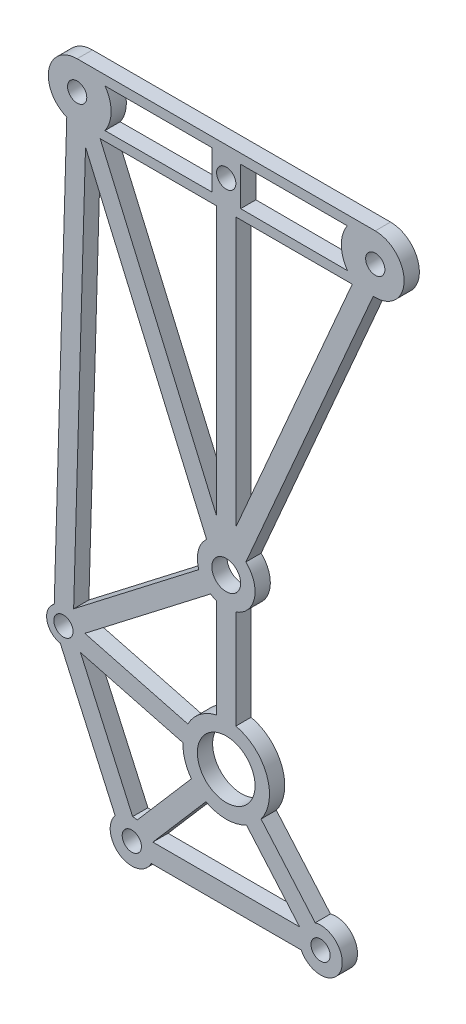
from build123d import *

# Parameters (mm, degrees)
SKETCH3_R           = 3
SKETCH3_R_2         = 1
SKETCH3_R_3         = 1.500000001
BOSS_EXTRUDE1_DEPTH = 1.5875


with BuildPart() as part:
    # Sketch3 → Boss-Extrude1 (new body)
    with BuildSketch(Plane.XY):
        with BuildLine():
            Line((-11.499999999, 31.641209076), (19.500000007, 31.641209076))
            ThreePointArc((19.500000007, 31.641209076), (22.500000018, 28.641209065), (19.500000007, 25.641209053))
            Line((19.500000007, 25.641209053), (19.289245586, 25.641209053))
            Line((19.289245586, 25.641209053), (6.042590494, -4.911559932))
            ThreePointArc((6.042590494, -4.911559932), (6.937456234, -7.718176584), (5, -9.937218057))
            Line((5, -9.937218057), (5, -20.212517806))
            ThreePointArc((5, -20.212517806), (8.217909302, -23.031803227), (7.623388784, -27.268530255))
            Line((7.623388784, -27.268530255), (13.255537043, -33.795798194))
            ThreePointArc((13.255537043, -33.795798194), (15.860860714, -36.911906153), (11.799598856, -36.975091304))
            Line((11.799598856, -36.975091304), (-3.799598854, -36.975091304))
            ThreePointArc((-3.799598854, -36.975091304), (-7.037028015, -37.86441568), (-7.553929711, -34.547088736))
            Line((-7.553929711, -34.547088736), (-13.250643923, -21.881287835))
            ThreePointArc((-13.250643923, -21.881287835), (-14.64398835, -20.503360892), (-13.885312196, -18.696567642))
            Line((-13.885312196, -18.696567642), (-12.58228364, 25.843234412))
            ThreePointArc((-12.58228364, 25.843234412), (-14.449061209, 29.191697969), (-11.499999999, 31.641209076))
        make_face()
        with Locations((4, -24.6)):
            Circle(SKETCH3_R, mode=Mode.SUBTRACT)
        with Locations((-12.927736724, -20.161336981)):
            Circle(SKETCH3_R_2, mode=Mode.SUBTRACT)
        with Locations((4, -7.108790933)):
            Circle(SKETCH3_R_3, mode=Mode.SUBTRACT)
        with Locations((-5.815163291, -35.975091304)):
            Circle(SKETCH3_R_2, mode=Mode.SUBTRACT)
        with Locations((13.815163293, -35.975091304)):
            Circle(SKETCH3_R_2, mode=Mode.SUBTRACT)
        with Locations((-11.499999999, 28.641209067)):
            Circle(SKETCH3_R_2, mode=Mode.SUBTRACT)
        with Locations((4, 28.641209067)):
            Circle(SKETCH3_R_2, mode=Mode.SUBTRACT)
        with Locations((19.500000007, 28.641209065)):
            Circle(SKETCH3_R_2, mode=Mode.SUBTRACT)
        Polygon((-9.109355809, 25.641209053), (3, 25.641209053), (3, -2.288434183), align=None, mode=Mode.SUBTRACT)
        with BuildLine():
            Line((5.500000007, 30.641209065), (5.500000007, 26.641209065))
            Line((5.500000007, 26.641209065), (16.612506499, 26.612956076))
            ThreePointArc((16.612506499, 26.612956076), (15.971383713, 28.624004515), (16.59286586, 30.641209065))
            Line((16.59286586, 30.641209065), (5.500000007, 30.641209065))
        make_face(mode=Mode.SUBTRACT)
        with BuildLine():
            Line((2.500000001, 30.641209067), (-8.592865852, 30.641209067))
            ThreePointArc((-8.592865852, 30.641209067), (-7.971383705, 28.624004518), (-8.612506491, 26.612956078))
            Line((-8.612506491, 26.612956078), (2.500000001, 26.641209067))
            Line((2.500000001, 26.641209067), (2.500000001, 30.641209067))
        make_face(mode=Mode.SUBTRACT)
        with BuildLine():
            Line((3, -20.212517806), (3, -9.937218057))
            ThreePointArc((3, -9.937218057), (2.676302312, -9.800969313), (2.370745742, -9.627824589))
            Line((2.370745742, -9.627824589), (-10.705156103, -19.710319003))
            Line((-10.705156103, -19.710319003), (0.009629689, -22.519869047))
            ThreePointArc((0.009629689, -22.519869047), (1.251015388, -21.03726459), (3, -20.212517806))
        make_face(mode=Mode.SUBTRACT)
        Polygon((5, 25.641209053), (17.109355816, 25.641209053), (5, -2.288434184), align=None, mode=Mode.SUBTRACT)
        with BuildLine():
            Line((1.149490439, -8.043988902), (-11.866425305, -18.080229562))
            Line((-11.866425305, -18.080229562), (-10.631706445, 24.124626881))
            Line((-10.631706445, 24.124626881), (1.957409506, -4.911559931))
            ThreePointArc((1.957409506, -4.911559931), (1.095067152, -6.359547882), (1.149490439, -8.043988902))
        make_face(mode=Mode.SUBTRACT)
        with BuildLine():
            Line((-3.631490152, -34.975091304), (11.631490154, -34.975091304))
            Line((11.631490154, -34.975091304), (6.109164807, -28.575100479))
            ThreePointArc((6.109164807, -28.575100479), (4, -29.1), (1.890835193, -28.575100479))
            Line((1.890835193, -28.575100479), (-3.631490152, -34.975091304))
        make_face(mode=Mode.SUBTRACT)
        with BuildLine():
            Line((-11.157493782, -21.659322937), (-0.497646084, -24.454467529))
            ThreePointArc((-0.497646084, -24.454467529), (-0.297387472, -25.935088354), (0.376611216, -27.268530255))
            Line((0.376611216, -27.268530255), (-5.255537041, -33.795798194))
            ThreePointArc((-5.255537041, -33.795798194), (-5.490888453, -33.748581518), (-5.729930654, -33.72670624))
            Line((-5.729930654, -33.72670624), (-11.157493782, -21.659322937))
        make_face(mode=Mode.SUBTRACT)
    extrude(amount=BOSS_EXTRUDE1_DEPTH)


solid = part.part
